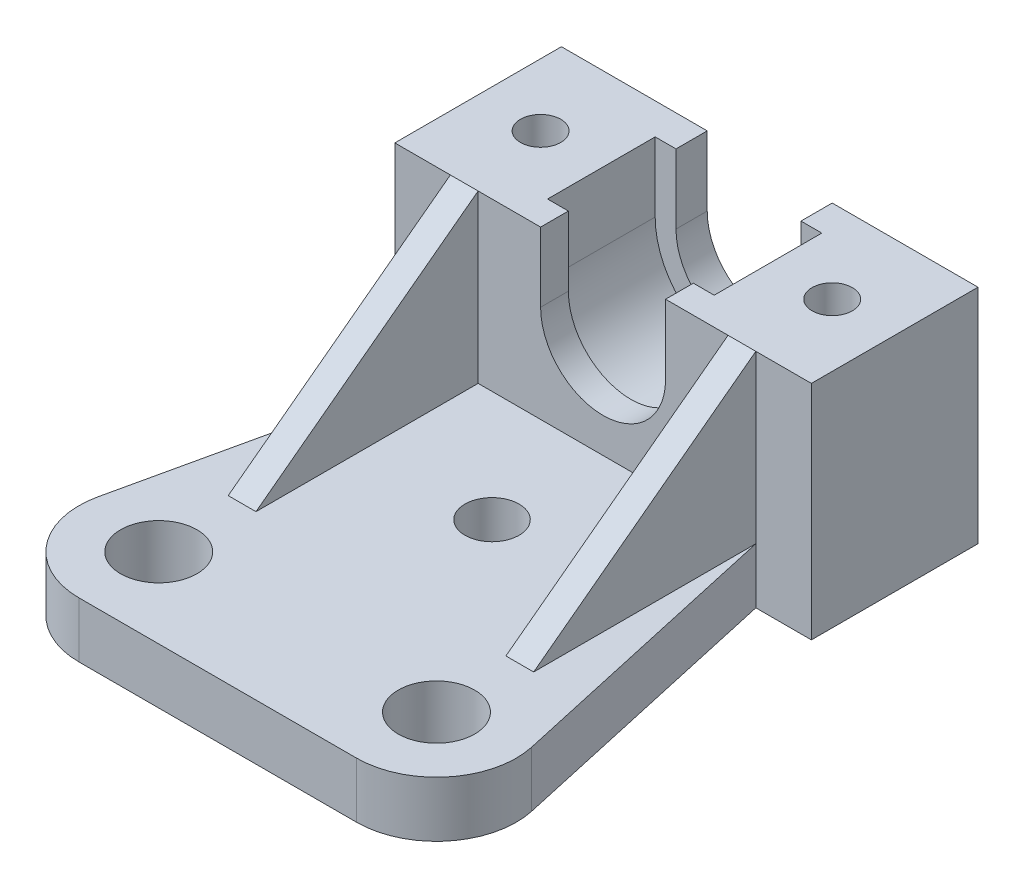
from build123d import *

# Parameters (mm, degrees)
BOSS_EXTRUDE1_DEPTH = 12
CUT_EXTRUDE1_START  = -2
CUT_EXTRUDE1_DEPTH  = 7.75
SKETCH3_R           = 1.45
CUT_EXTRUDE2_DEPTH  = 18
SKETCH4_W           = 22
SKETCH4_H           = 4
BOSS_EXTRUDE2_DEPTH = 16
SKETCH5_R           = 1.95
CUT_EXTRUDE3_DEPTH  = 14.5
BOSS_EXTRUDE3_DEPTH = 2
BOSS_EXTRUDE4_START = -22
BOSS_EXTRUDE4_DEPTH = 2
SKETCH7_R           = 2.75
BOSS_EXTRUDE5_DEPTH = 4


with BuildPart() as part:
    # Sketch1 → Boss-Extrude1 (new body)
    with BuildSketch(Plane.XY):
        with BuildLine():
            Line((-5.280588843, 25), (-5.280588843, 41))
            Line((-5.280588843, 41), (5.219411157, 41))
            Line((5.219411157, 41), (5.219411157, 36))
            ThreePointArc((5.219411157, 36), (9.719411157, 31.5), (14.219411157, 36))
            Line((14.219411157, 36), (14.219411157, 41))
            Line((14.219411157, 41), (24.719411157, 41))
            Line((24.719411157, 41), (24.719411157, 25))
            Line((24.719411157, 25), (9.719411157, 25))
            Line((9.719411157, 25), (-5.280588843, 25))
        make_face()
    extrude(amount=-BOSS_EXTRUDE1_DEPTH)

    # Sketch2 → Cut-Extrude1 (cut)
    with BuildSketch(Plane.XY.offset(CUT_EXTRUDE1_START)):
        with BuildLine():
            Line((3.719411157, 36), (3.719411157, 41))
            Line((3.719411157, 41), (15.719411157, 41))
            Line((15.719411157, 41), (15.719411157, 36))
            ThreePointArc((15.719411157, 36), (9.719411157, 30), (3.719411157, 36))
        make_face()
    extrude(amount=-CUT_EXTRUDE1_DEPTH, mode=Mode.SUBTRACT)

    # Sketch3 → Cut-Extrude2 (cut)
    with BuildSketch(Plane(origin=(0, 41, 0), x_dir=(1, 0, 0), z_dir=(0, 1, 0))):
        with Locations((20.219411157, 6)):
            Circle(SKETCH3_R)
        with Locations((-0.780588843, 6)):
            Circle(SKETCH3_R)
    extrude(amount=-CUT_EXTRUDE2_DEPTH, mode=Mode.SUBTRACT)

    # Sketch4 → Boss-Extrude2 (add)
    with BuildSketch(Plane.XY):
        with Locations((9.719411157, 27)):
            Rectangle(SKETCH4_W, SKETCH4_H)
    extrude(amount=BOSS_EXTRUDE2_DEPTH)

    # Sketch5 → Cut-Extrude3 (cut, symmetric)
    with BuildSketch(Plane(origin=(0, 29, 0), x_dir=(1, 0, 0), z_dir=(0, 1, 0))):
        with Locations((9.719411157, -8)):
            Circle(SKETCH5_R)
    extrude(amount=CUT_EXTRUDE3_DEPTH, both=True, mode=Mode.SUBTRACT)

    # Sketch6 → Boss-Extrude3 (add)
    with BuildSketch(Plane.ZY.offset(1.280588843)):
        Polygon((16, 29), (0, 41), (0, 29), align=None)
    extrude(amount=-BOSS_EXTRUDE3_DEPTH)

    # Sketch6_2 → Boss-Extrude4 (add)
    with BuildSketch(Plane.ZY.offset(1.280588843).offset(BOSS_EXTRUDE4_START)):
        Polygon((16, 29), (0, 41), (0, 29), align=None)
    extrude(amount=BOSS_EXTRUDE4_DEPTH)

    # Sketch7 → Boss-Extrude5 (add)
    with BuildSketch(Plane(origin=(0, 25, 0), x_dir=(-1, 0, 0), z_dir=(0, -1, 0))):
        with BuildLine():
            Line((1.280588843, 0), (5.893585637, -20.752295309))
            ThreePointArc((5.893585637, -20.752295309), (4.765942897, -25.597790852), (0.280588843, -27.75))
            Line((0.280588843, -27.75), (-19.719411157, -27.75))
            ThreePointArc((-19.719411157, -27.75), (-24.204765211, -25.597790852), (-25.33240795, -20.752295309))
            Line((-25.33240795, -20.752295309), (-20.719411157, 0))
            Line((-20.719411157, 0), (-20.719411157, -16))
            Line((-20.719411157, -16), (1.280588843, -16))
            Line((1.280588843, -16), (1.280588843, 0))
        make_face()
        with Locations((0.280588843, -22)):
            Circle(SKETCH7_R, mode=Mode.SUBTRACT)
        with Locations((-19.719411157, -22)):
            Circle(SKETCH7_R, mode=Mode.SUBTRACT)
    extrude(amount=-BOSS_EXTRUDE5_DEPTH)


solid = part.part
